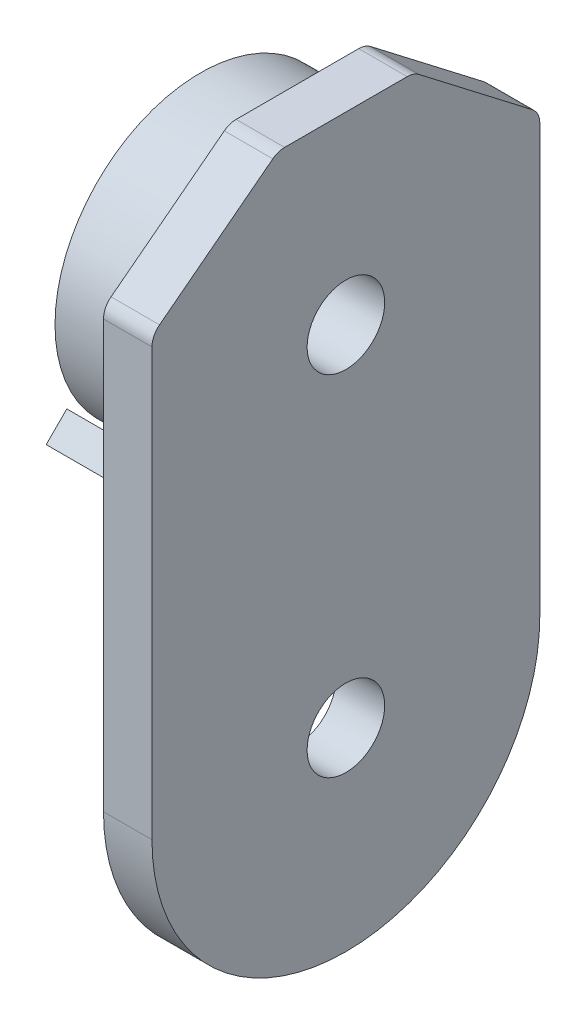
from build123d import *

# Parameters (mm, degrees)
AUFSATZ_LINEAR_AUSTRAGEN1_DEPTH = 5
VERRUNDUNG2_R                   = 2
SKIZZE7_R                       = 15
AUFSATZ_LINEAR_AUSTRAGEN3_DEPTH = 10
AUFSATZ_LINEAR_AUSTRAGEN5_DEPTH = 10
SCHNITT_LINEAR_AUSTRAGEN2_REACH = 17
SKIZZE9_R                       = 4
SCHNITT_LINEAR_AUSTRAGEN3_REACH = 7
SKIZZE10_R                      = 4


with BuildPart() as part:
    # Skizze1 → Aufsatz-Linear austragen1 (new body)
    with BuildSketch(Plane(origin=(0, 0, 0), x_dir=(0, 0, -1), z_dir=(1, 0, 0))):
        with BuildLine():
            Line((-20, 0), (-20, 45))
            Line((-20, 45), (-7, 55))
            Line((-7, 55), (7, 55))
            Line((7, 55), (20, 45))
            Line((20, 45), (20, 0))
            ThreePointArc((20, 0), (0, -20), (-20, 0))
        make_face()
    extrude(amount=-AUFSATZ_LINEAR_AUSTRAGEN1_DEPTH)

    # Verrundung2
    verrundung2_edges = [part.edges().sort_by_distance(p)[0] for p in [
        (-2.5, 45, 20),
        (-2.5, 55, 7),
        (-2.5, 55, -7),
        (-2.5, 45, -20),
    ]]
    fillet(verrundung2_edges, radius=VERRUNDUNG2_R)

    # Skizze7 → Aufsatz-Linear austragen3 (add)
    with BuildSketch(Plane.ZY.offset(5)):
        with Locations((0, 36)):
            Circle(SKIZZE7_R)
    extrude(amount=AUFSATZ_LINEAR_AUSTRAGEN3_DEPTH)

    # Skizze8 → Aufsatz-Linear austragen5 (add)
    with BuildSketch(Plane.ZY.offset(5)):
        with BuildLine():
            Line((15.909902577, 25.746951673), (10.253048327, 20.090097423))
            Line((10.253048327, 20.090097423), (8.126024025, 22.217121725))
            ThreePointArc((8.126024025, 22.217121725), (11.313708499, 24.686291501), (13.782878275, 27.873975975))
            Line((13.782878275, 27.873975975), (15.909902577, 25.746951673))
        make_face()
    aufsatz_linear_austragen5 = extrude(amount=AUFSATZ_LINEAR_AUSTRAGEN5_DEPTH)

    # Spiegeln2: Aufsatz-Linear austragen5 across plane
    add(aufsatz_linear_austragen5.mirror(Plane.XY))

    # Skizze9 → Schnitt-Linear austragen2 (cut, up to next)
    with BuildSketch(Plane.ZY.offset(15), mode=Mode.PRIVATE) as schnitt_linear_austragen2_sk1:
        with Locations((0, 36)):
            Circle(SKIZZE9_R)
    schnitt_linear_austragen2_tool1 = extrude(schnitt_linear_austragen2_sk1.sketch, amount=-SCHNITT_LINEAR_AUSTRAGEN2_REACH, mode=Mode.PRIVATE) & part.part
    add(schnitt_linear_austragen2_tool1.solids().sort_by_distance((-15, 36, 0))[0], mode=Mode.SUBTRACT)

    # Skizze10 → Schnitt-Linear austragen3 (cut, up to next)
    with BuildSketch(Plane.ZY.offset(5), mode=Mode.PRIVATE) as schnitt_linear_austragen3_sk1:
        Circle(SKIZZE10_R)
    schnitt_linear_austragen3_tool1 = extrude(schnitt_linear_austragen3_sk1.sketch, amount=-SCHNITT_LINEAR_AUSTRAGEN3_REACH, mode=Mode.PRIVATE) & part.part
    add(schnitt_linear_austragen3_tool1.solids().sort_by_distance((-5, 0, 0))[0], mode=Mode.SUBTRACT)


solid = part.part
